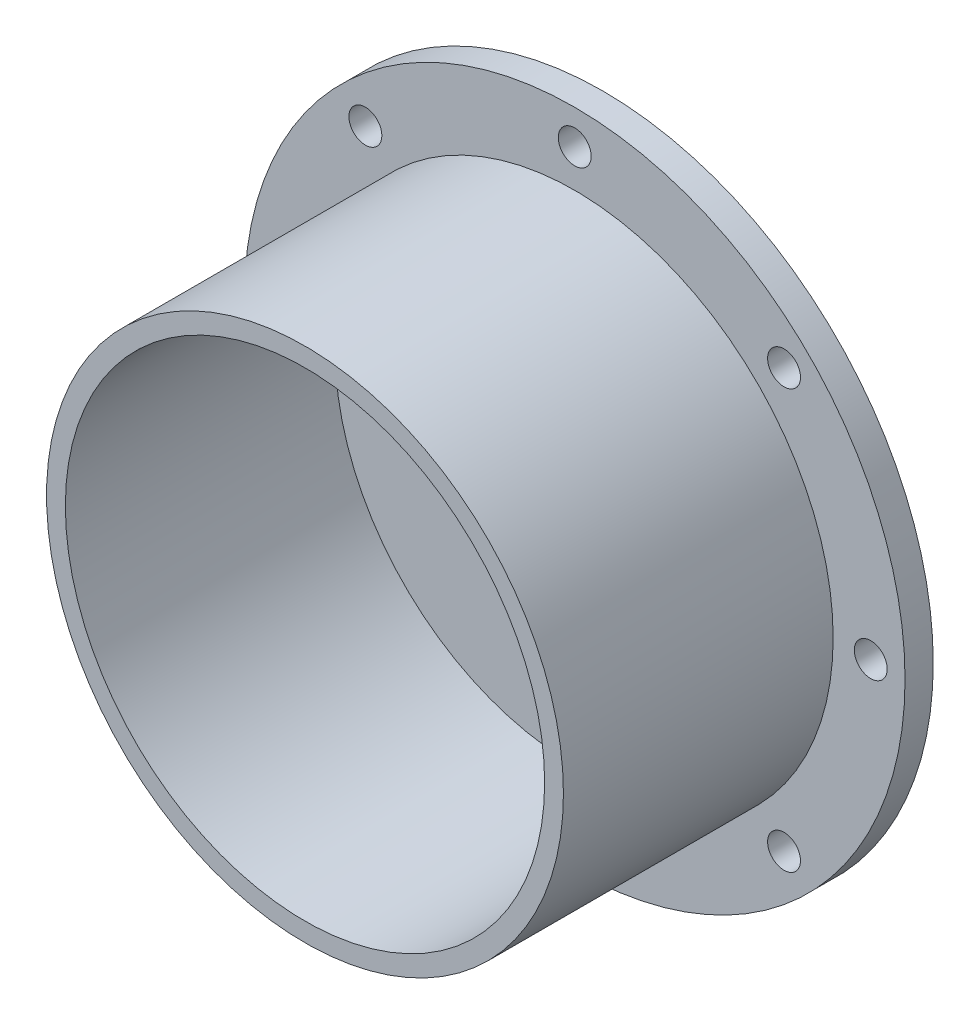
from build123d import *

# Parameters (mm, degrees)
SKETCH1_R           = 35.15
SKETCH1_R_2         = 1.75
BOSS_EXTRUDE2_DEPTH = 3
SKETCH3_R           = 27.5
SKETCH3_R_2         = 25.5
BOSS_EXTRUDE3_DEPTH = 28.7


with BuildPart() as part:
    # Sketch1 → Boss-Extrude2 (new body)
    with BuildSketch(Plane.XY):
        Circle(SKETCH1_R)
        with Locations((0, 31.5)):
            Circle(SKETCH1_R_2, mode=Mode.SUBTRACT)
        with Locations((22.273863607, 22.273863607)):
            Circle(SKETCH1_R_2, mode=Mode.SUBTRACT)
        with Locations((31.5, 0)):
            Circle(SKETCH1_R_2, mode=Mode.SUBTRACT)
        with Locations((22.273863607, -22.273863607)):
            Circle(SKETCH1_R_2, mode=Mode.SUBTRACT)
        with Locations((0, -31.5)):
            Circle(SKETCH1_R_2, mode=Mode.SUBTRACT)
        with Locations((-22.273863607, -22.273863607)):
            Circle(SKETCH1_R_2, mode=Mode.SUBTRACT)
        with Locations((-31.5, 0)):
            Circle(SKETCH1_R_2, mode=Mode.SUBTRACT)
        with Locations((-22.273863607, 22.273863607)):
            Circle(SKETCH1_R_2, mode=Mode.SUBTRACT)
    extrude(amount=BOSS_EXTRUDE2_DEPTH)

    # Sketch3 → Boss-Extrude3 (add)
    with BuildSketch(Plane.XY.offset(3)):
        Circle(SKETCH3_R)
        Circle(SKETCH3_R_2, mode=Mode.SUBTRACT)
    extrude(amount=BOSS_EXTRUDE3_DEPTH)


solid = part.part
